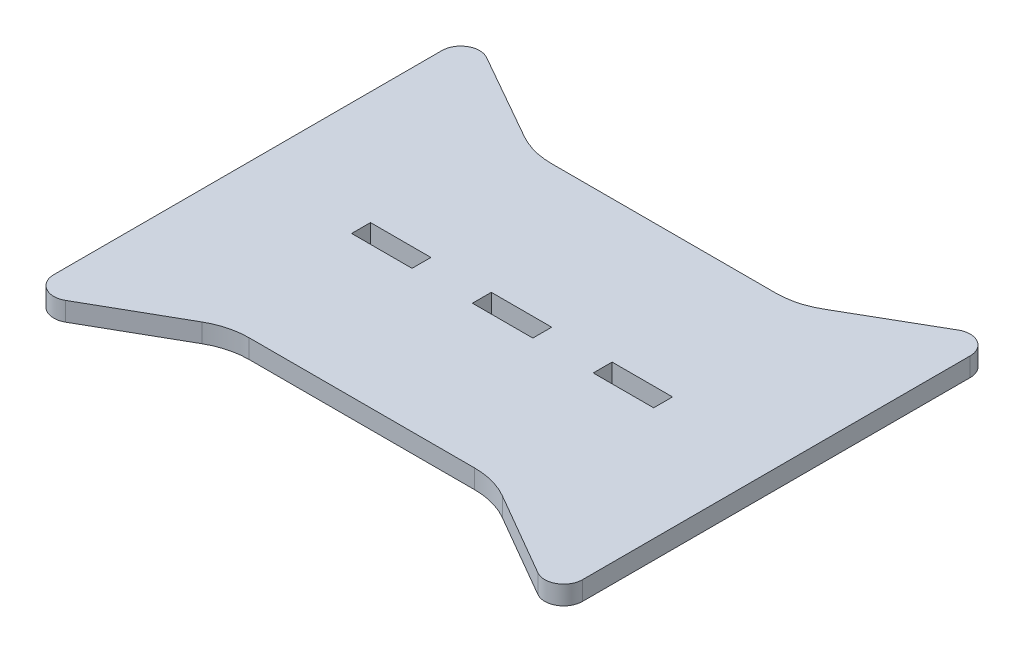
from build123d import *

# Parameters (mm, degrees)
SKETCH1_W           = 16
SKETCH1_H           = 5
BOSS_EXTRUDE1_DEPTH = 5


with BuildPart() as part:
    # Sketch1 → Boss-Extrude1 (new body)
    with BuildSketch(Plane(origin=(0, 0, 0), x_dir=(1, 0, 0), z_dir=(0, 1, 0))):
        with BuildLine():
            Line((-29.495397245, 40), (29.879619523, 40))
            ThreePointArc((29.879619523, 40), (35.039273824, 40.677009354), (39.849614703, 42.662203251))
            Line((39.849614703, 42.662203251), (62.507501205, 55.691483874))
            ThreePointArc((62.507501205, 55.691483874), (67.503747793, 55.684995753), (70, 51.357034687))
            Line((70, 51.357034687), (70, -51.328756138))
            ThreePointArc((70, -51.328756138), (67.497622519, -55.660254926), (62.495247299, -55.656135704))
            Line((62.495247299, -55.656135704), (40.094909722, -42.690481736))
            ThreePointArc((40.094909722, -42.690481736), (35.262884302, -40.684328056), (30.075898919, -40))
            Line((30.075898919, -40), (-29.621741739, -40))
            ThreePointArc((-29.621741739, -40), (-34.74594239, -40.667577294), (-39.528063042, -42.625743232))
            Line((-39.528063042, -42.625743232), (-62.523419674, -55.737060414))
            ThreePointArc((-62.523419674, -55.737060414), (-67.511682541, -55.716857277), (-70, -51.393496222))
            Line((-70, -51.393496222), (-70, 51.411080519))
            ThreePointArc((-70, 51.411080519), (-67.515524189, 55.732207462), (-62.531144779, 55.759040259))
            Line((-62.531144779, 55.759040259), (-39.370818131, 42.608161042))
            ThreePointArc((-39.370818131, 42.608161042), (-34.602413049, 40.663030497), (-29.495397245, 40))
        make_face()
        Rectangle(SKETCH1_W, SKETCH1_H, mode=Mode.SUBTRACT)
        with Locations((-32, 0)):
            Rectangle(SKETCH1_W, SKETCH1_H, mode=Mode.SUBTRACT)
        with Locations((32, 0)):
            Rectangle(SKETCH1_W, SKETCH1_H, mode=Mode.SUBTRACT)
    extrude(amount=BOSS_EXTRUDE1_DEPTH)


solid = part.part
